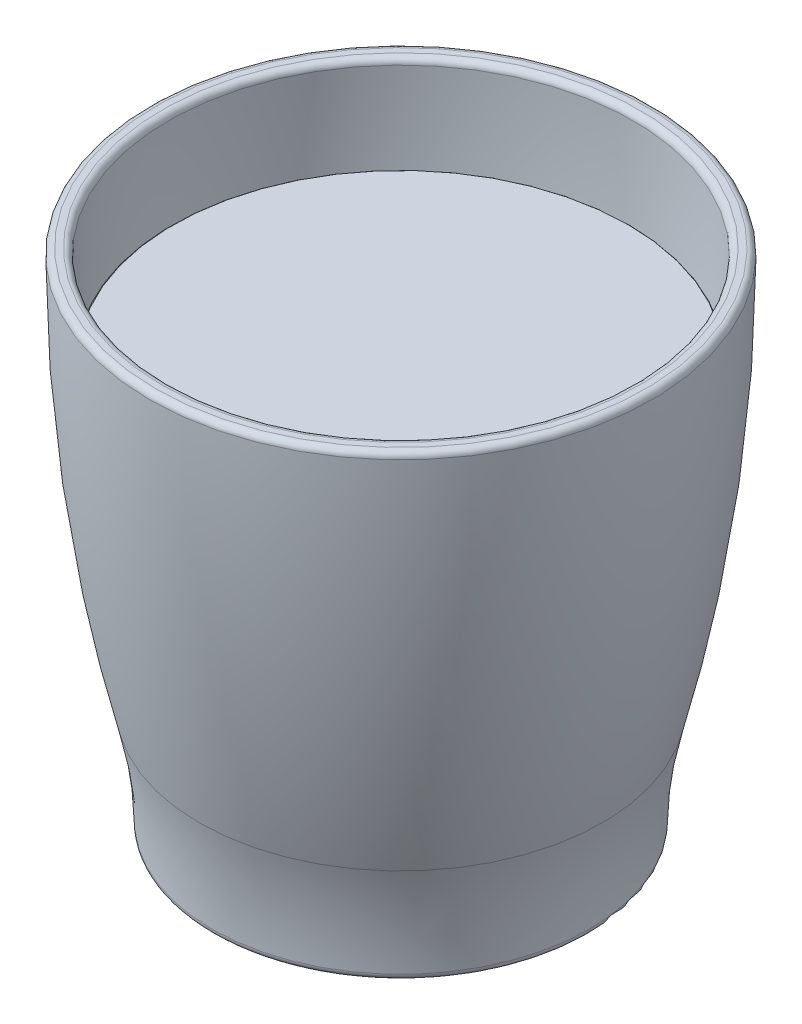
from build123d import *

# Parameters (mm, degrees)
FILLET1_R = 1
FILLET2_R = 0.1


with BuildPart() as part:
    # Sketch1 → Revolve1 (revolve)
    with BuildSketch(Plane.XY):
        with BuildLine():
            Line((-30.011977453, 0), (-24.141284524, 0))
            ThreePointArc((-24.141284524, 0), (-20.306375732, 1.706241198), (-16.275355933, 2.876140276))
            Line((-16.275355933, 2.876140276), (0, 2.876140276))
            Line((0, 2.876140276), (0, 7.876140276))
            Line((0, 7.876140276), (-16.792967571, 7.876140276))
            ThreePointArc((-16.792967571, 7.876140276), (-16.867013835, 7.861140117), (-16.941028324, 7.845983949))
            ThreePointArc((-16.941028324, 7.845983949), (-24.387747433, 9.243440319), (-28.71712338, 15.461399286))
            ThreePointArc((-28.71712338, 15.461399286), (-28.946402501, 16.454646489), (-29.189927839, 17.44449715))
            ThreePointArc((-29.189927839, 17.44449715), (-35.039931925, 48.479418771), (-37, 80))
            Line((-37, 80), (-40, 80))
            ThreePointArc((-40, 80), (-38.016820378, 48.107753409), (-32.097837745, 16.706892934))
            ThreePointArc((-32.097837745, 16.706892934), (-30.535458937, 8.418299779), (-30.011977453, 0))
        make_face()
    revolve(axis=Axis((0, 7.876140276, 0), (0, -1, 0)))

    # Fillet1
    fillet1_edges = [part.edges().sort_by_distance(p)[0] for p in [
        (24.141284524, 0, 0),
        (30.011977453, 0, 0),
        (40, 80, 0),
        (37, 80, 0),
    ]]
    fillet(fillet1_edges, radius=FILLET1_R)


with BuildPart() as body_2:
    # Sketch2 → Revolve2 (revolve)
    with BuildSketch(Plane.XY):
        with BuildLine():
            Line((-36.357096479, 65), (0, 65))
            Line((0, 65), (0, 8.076140276))
            Line((0, 8.076140276), (-16.812887273, 8.076140276))
            ThreePointArc((-16.812887273, 8.076140276), (-16.897142459, 8.05910846), (-16.981356795, 8.041875792))
            ThreePointArc((-16.981356795, 8.041875792), (-24.279141522, 9.411383036), (-28.521929949, 15.504982823))
            ThreePointArc((-28.521929949, 15.504982823), (-28.751855376, 16.501029852), (-28.996067179, 17.493670765))
            ThreePointArc((-28.996067179, 17.493670765), (-33.802007536, 41.072452479), (-36.357096479, 65))
        make_face()
    revolve(axis=Axis((0, 0, 0), (0, 1, 0)))

    # Fillet2
    fillet2_edges = [body_2.edges().sort_by_distance(p)[0] for p in [
        (36.357096479, 65, 0),
    ]]
    fillet(fillet2_edges, radius=FILLET2_R)


solid = Compound([part.part, body_2.part])
